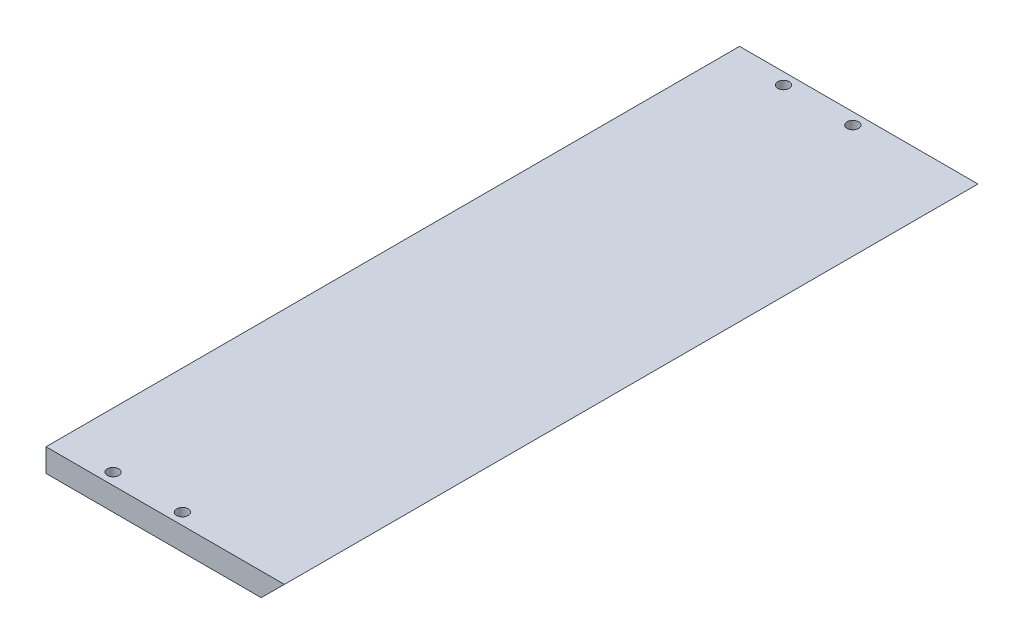
from build123d import *

# Parameters (mm, degrees)
BOSS_EXTRUDE1_DEPTH   = 75
M3X0_5_TAPPED_HOLE1_D = 2.5


with BuildPart() as part:
    # Sketch1 → Boss-Extrude1 (new body, symmetric)
    with BuildSketch(Plane.XY):
        Polygon((51.57, 5), (46.53, 0), (0, 0), (0, 5), align=None)
    extrude(amount=BOSS_EXTRUDE1_DEPTH, both=True)

    # M3x0.5 Tapped Hole1 (through all)
    with Locations(Plane(origin=(0, 5, 0), x_dir=(1, 0, 0), z_dir=(0, 1, 0))):
        with Locations((12, -72.5), (27, -72.5)):
            m3x0_5_tapped_hole1 = Hole(M3X0_5_TAPPED_HOLE1_D / 2)

    # Mirror1: M3x0.5 Tapped Hole1 across plane
    add(m3x0_5_tapped_hole1.mirror(Plane.XY), mode=Mode.SUBTRACT)


solid = part.part
